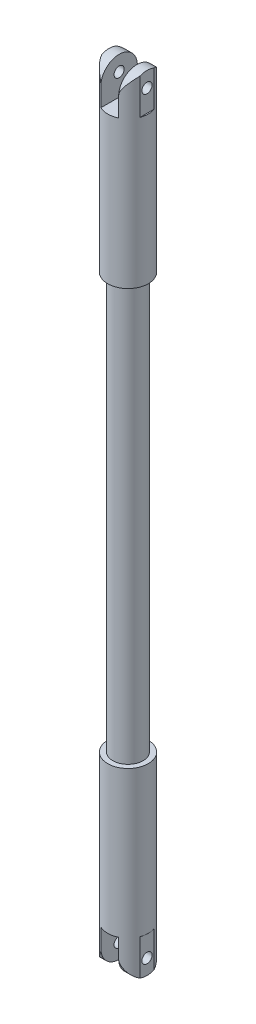
from build123d import *

# Parameters (mm, degrees)
SKETCH2_W               = 3.5
SKETCH2_H               = 22
SKETCH2_W_2             = 3.489149722
SKETCH2_H_2             = 10.808558849
SKETCH2_W_3             = 5.104041679
SKETCH2_H_3             = 8.66936491
CUT_EXTRUDE1_DEPTH      = 10
SKETCH3_R               = 1
CUT_EXTRUDE2_DEPTH      = 1.25
CUT_EXTRUDE2_DEPTH_BACK = 8.75
CUT_EXTRUDE3_DEPTH      = 1.25
CUT_EXTRUDE3_DEPTH_BACK = 8.75


with BuildPart() as part:
    # Sketch1 → Revolve1 (revolve)
    with BuildSketch(Plane.XY, mode=Mode.PRIVATE) as revolve1_sk:
        Polygon((0, -75), (0, 75), (-3, 75), (-3, -35), (-4, -35), (-4, -75), align=None)
    revolve(revolve1_sk.sketch.rotate(Axis((0, -75, 0), (0, 1, 0)), 180), axis=Axis((0, -75, 0), (0, 1, 0)))  # turned: the seam where the file's is

    # Sketch2 → Cut-Extrude1 (cut, symmetric)
    with BuildSketch(Plane.XY):
        with Locations((0, -75)):
            Rectangle(SKETCH2_W, SKETCH2_H)
        with Locations((-5.494574861, -69.404279425)):
            Rectangle(SKETCH2_W_2, SKETCH2_H_2)
        with Locations((6.302020839, -68.334682455)):
            Rectangle(SKETCH2_W_3, SKETCH2_H_3)
    extrude(amount=CUT_EXTRUDE1_DEPTH, both=True, mode=Mode.SUBTRACT)

    # Sketch3 → Cut-Extrude2 (cut, two sides)
    with BuildSketch(Plane(origin=(3.75, 0, 0), x_dir=(0, 0, -1), z_dir=(1, 0, 0))) as cut_extrude2_sk:
        with Locations(Location((0, -68.334682455, 0), (0, 0, 90))):  # turned: the seam where the file's is
            Circle(SKETCH3_R)
    extrude(amount=CUT_EXTRUDE2_DEPTH, mode=Mode.SUBTRACT)
    extrude(cut_extrude2_sk.sketch, amount=-CUT_EXTRUDE2_DEPTH_BACK, mode=Mode.SUBTRACT)

    # Sketch4 → Cut-Extrude3 (cut, two sides)
    with BuildSketch(Plane(origin=(3.75, 0, 0), x_dir=(0, 0, -1), z_dir=(1, 0, 0))) as cut_extrude3_sk:
        with BuildLine():
            Line((-3.596873642, -67.828802158), (-5.675638146, -67.828802158))
            Line((-5.675638146, -67.828802158), (-5.675638146, -76.926900892))
            Line((-5.675638146, -76.926900892), (6.407188639, -76.926900892))
            Line((6.407188639, -76.926900892), (6.407188639, -67.828802158))
            Line((6.407188639, -67.828802158), (3.596873642, -67.828802158))
            ThreePointArc((3.596873642, -67.828802158), (0, -71.334682455), (-3.596873642, -67.828802158))
        make_face()
    extrude(amount=CUT_EXTRUDE3_DEPTH, mode=Mode.SUBTRACT)
    extrude(cut_extrude3_sk.sketch, amount=-CUT_EXTRUDE3_DEPTH_BACK, mode=Mode.SUBTRACT)

    # Split1
    split(bisect_by=Plane.ZX.offset(6), keep=Keep.BOTTOM)

    # Mirror1: part across plane


with BuildPart() as part_1:
    add(part.part)
    add(part.part.mirror(Plane.ZX.offset(6)))


solid = part_1.part
